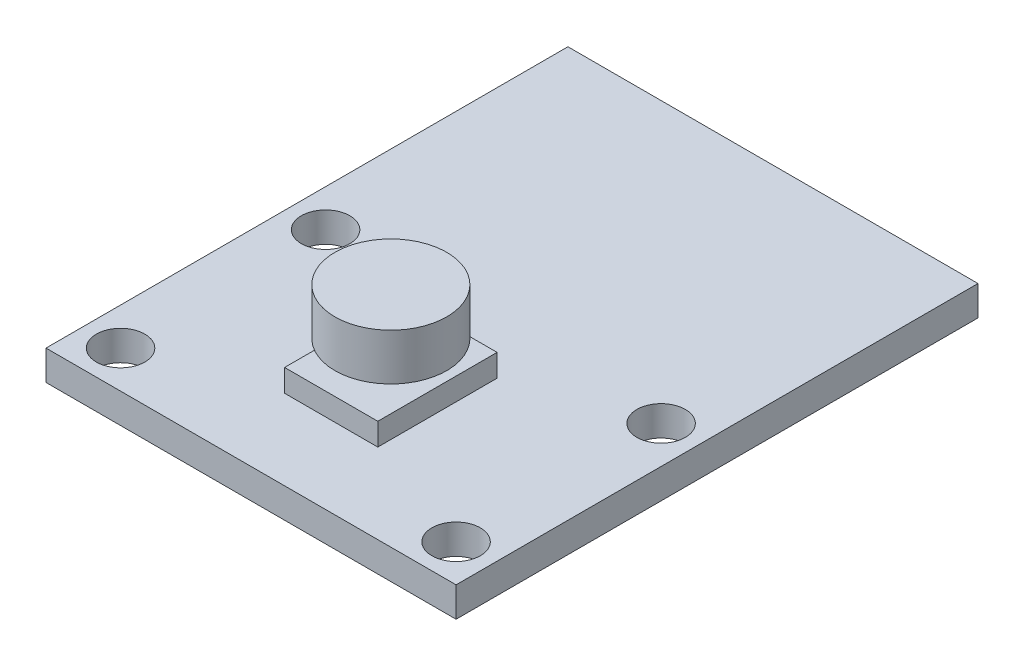
from build123d import *

# Parameters (mm, degrees)
ESQUISSE1_W        = 22
ESQUISSE1_H        = 28
ESQUISSE1_R        = 1.3
BOSS_EXTRU_1_DEPTH = 1.6
ESQUISSE2_W        = 5
ESQUISSE2_H        = 6.4
BOSS_EXTRU_2_DEPTH = 1.2
BOSS_EXTRU_3_START = 1
ESQUISSE3_R        = 3
BOSS_EXTRU_3_DEPTH = 2.5


with BuildPart() as part:
    # Esquisse1 → Boss.-Extru.1 (new body)
    with BuildSketch(Plane(origin=(0, 0, 0), x_dir=(1, 0, 0), z_dir=(0, 1, 0))):
        with Locations((0, 6.5)):
            Rectangle(ESQUISSE1_W, ESQUISSE1_H)
        with Locations((-9, 5.5)):
            Circle(ESQUISSE1_R, mode=Mode.SUBTRACT)
        with Locations((9, 5.5)):
            Circle(ESQUISSE1_R, mode=Mode.SUBTRACT)
        with Locations((9, -5.5)):
            Circle(ESQUISSE1_R, mode=Mode.SUBTRACT)
        with Locations((-9, -5.5)):
            Circle(ESQUISSE1_R, mode=Mode.SUBTRACT)
    extrude(amount=BOSS_EXTRU_1_DEPTH)

    # Esquisse2 → Boss.-Extru.2 (add)
    with BuildSketch(Plane(origin=(0, 1.6, 0), x_dir=(1, 0, 0), z_dir=(0, 1, 0))):
        Rectangle(ESQUISSE2_W, ESQUISSE2_H)
    extrude(amount=BOSS_EXTRU_2_DEPTH)


with BuildPart() as body_2:
    # Esquisse3 → Boss.-Extru.3 (new body)
    with BuildSketch(Plane(origin=(0, 2.8, 0), x_dir=(1, 0, 0), z_dir=(0, 1, 0)).offset(BOSS_EXTRU_3_START)):
        Circle(ESQUISSE3_R)
    extrude(amount=BOSS_EXTRU_3_DEPTH)


solid = Compound([part.part, body_2.part])
